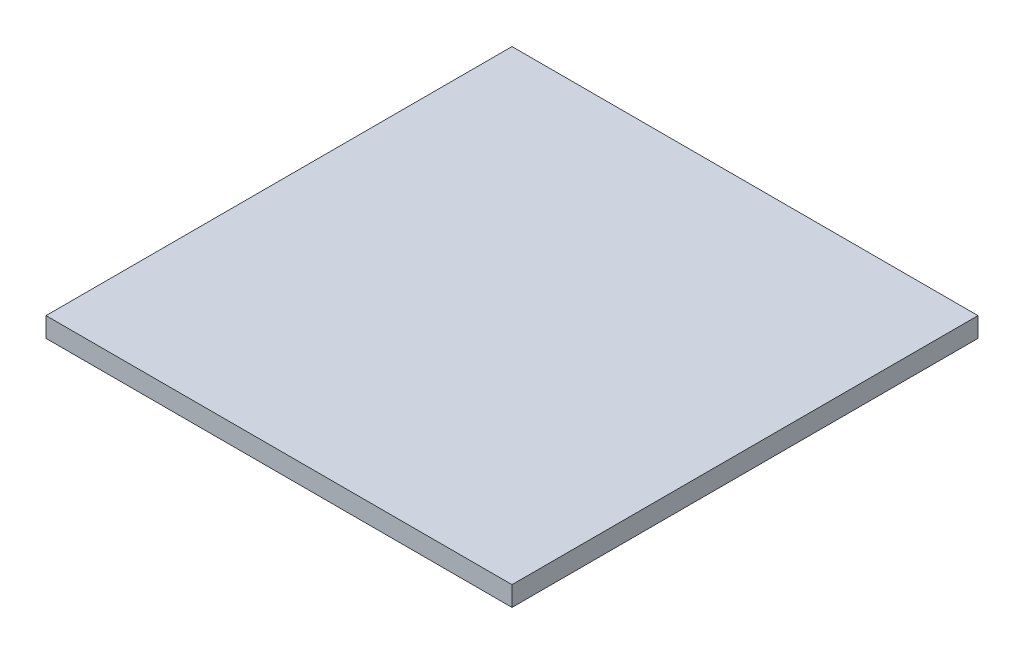
from build123d import *

# Parameters (mm, degrees)
SKETCH1_W           = 299.7
SKETCH1_H           = 299.7
BOSS_EXTRUDE1_DEPTH = 12.7


with BuildPart() as part:
    # Sketch1 → Boss-Extrude1 (new body)
    with BuildSketch(Plane(origin=(0, 0, 0), x_dir=(1, 0, 0), z_dir=(0, 1, 0))):
        Rectangle(SKETCH1_W, SKETCH1_H)
    extrude(amount=BOSS_EXTRUDE1_DEPTH)


solid = part.part
